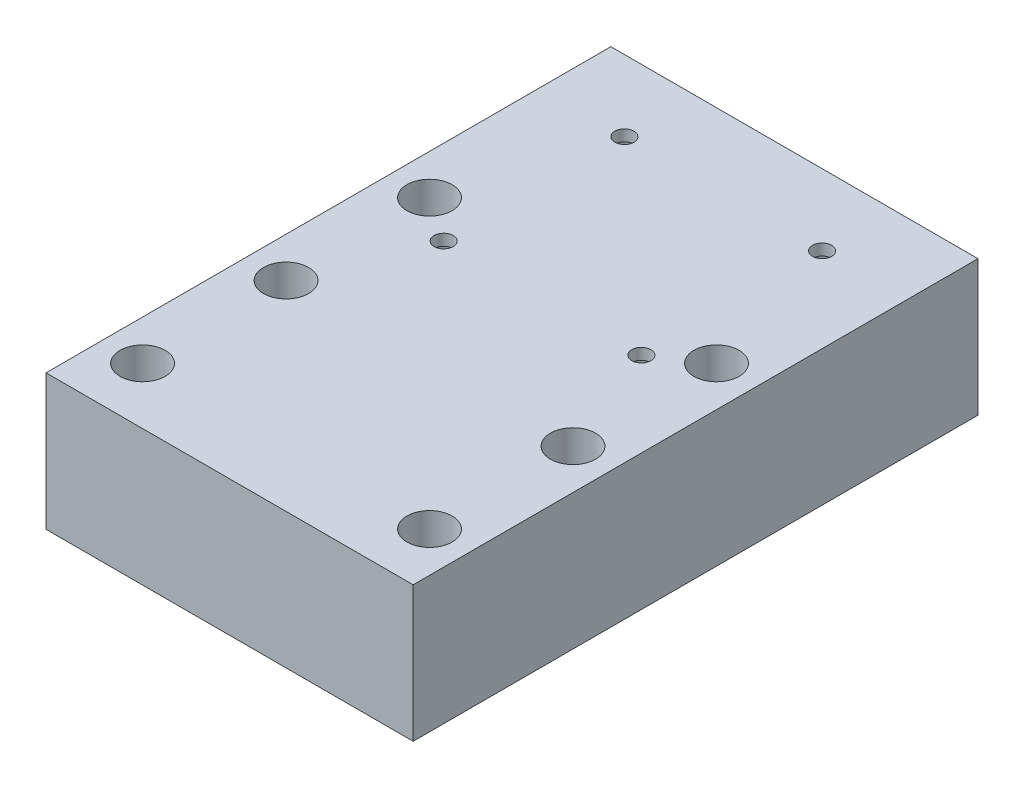
from build123d import *

# Parameters (mm, degrees)
SKETCH1_W           = 65
SKETCH1_H           = 100
SKETCH1_R           = 4
SKETCH1_R_2         = 1.7
BOSS_EXTRUDE1_DEPTH = 24
SKETCH3_R           = 3.5
CUT_EXTRUDE1_DEPTH  = 22


with BuildPart() as part:
    # Sketch1 → Boss-Extrude1 (new body)
    with BuildSketch(Plane(origin=(0, 0, 0), x_dir=(1, 0, 0), z_dir=(0, 1, 0))):
        Rectangle(SKETCH1_W, SKETCH1_H)
        with Locations((-25.4, -40)):
            Circle(SKETCH1_R, mode=Mode.SUBTRACT)
        with Locations((25.4, -40)):
            Circle(SKETCH1_R, mode=Mode.SUBTRACT)
        with Locations((25.4, -14.6)):
            Circle(SKETCH1_R, mode=Mode.SUBTRACT)
        with Locations((-25.4, -14.6)):
            Circle(SKETCH1_R, mode=Mode.SUBTRACT)
        with Locations((-17.5, 5.4)):
            Circle(SKETCH1_R_2, mode=Mode.SUBTRACT)
        with Locations((17.5, 37.4)):
            Circle(SKETCH1_R_2, mode=Mode.SUBTRACT)
        with Locations((-17.5, 37.4)):
            Circle(SKETCH1_R_2, mode=Mode.SUBTRACT)
        with Locations((17.5, 5.4)):
            Circle(SKETCH1_R_2, mode=Mode.SUBTRACT)
        with Locations((25.4, 10.8)):
            Circle(SKETCH1_R, mode=Mode.SUBTRACT)
        with Locations((-25.4, 10.8)):
            Circle(SKETCH1_R, mode=Mode.SUBTRACT)
    extrude(amount=BOSS_EXTRUDE1_DEPTH)

    # Sketch3 → Cut-Extrude1 (cut)
    with BuildSketch(Plane.XZ):
        with Locations((-17.5, -5.4)):
            Circle(SKETCH3_R)
        with Locations((17.5, -5.4)):
            Circle(SKETCH3_R)
        with Locations((-17.5, -37.4)):
            Circle(SKETCH3_R)
        with Locations((17.5, -37.4)):
            Circle(SKETCH3_R)
    extrude(amount=-CUT_EXTRUDE1_DEPTH, mode=Mode.SUBTRACT)


solid = part.part
